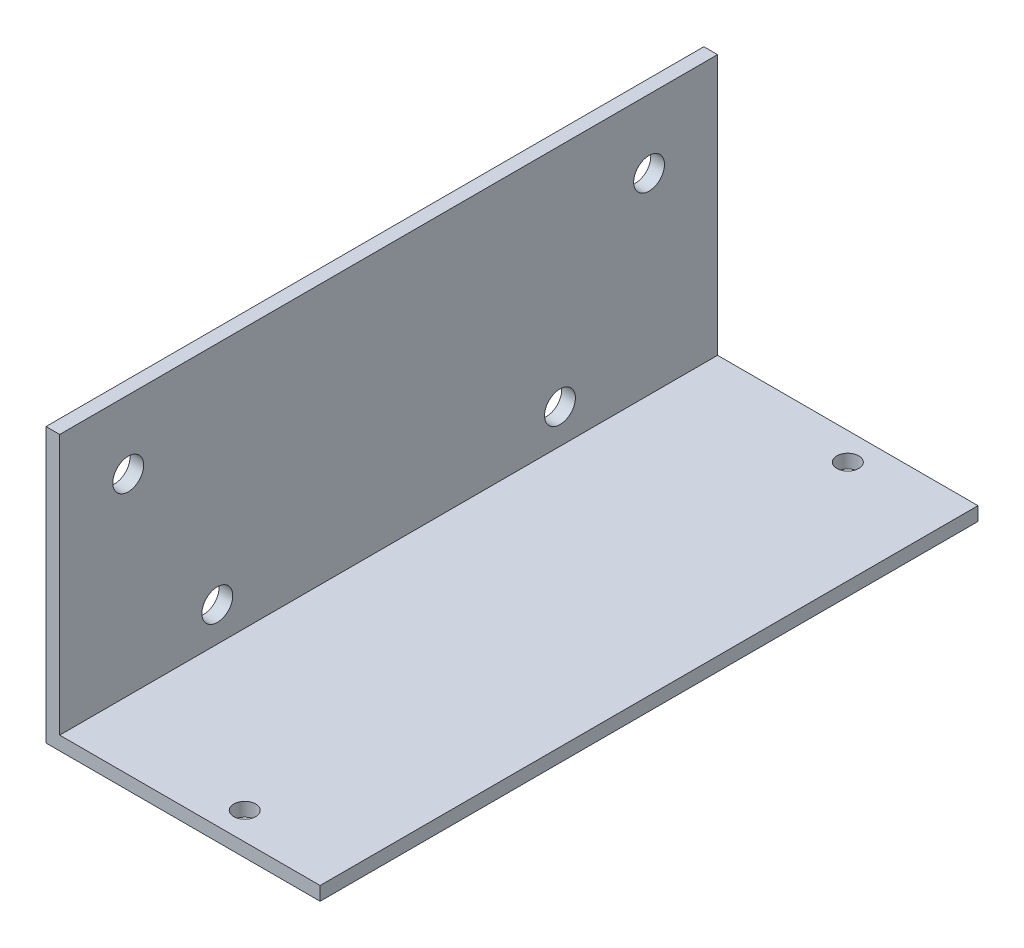
from build123d import *

# Parameters (mm, degrees)
EXTRUDE_1_DEPTH     = 96
SKETCH_2_R          = 1.6
CUT_EXTRUDE_1_DEPTH = 41
SKETCH_3_R          = 2.25
CUT_EXTRUDE_2_DEPTH = 41


with BuildPart() as part:
    # Эскиз1 → Бобышка-Вытянуть1 (new body)
    with BuildSketch(Plane.XY):
        Polygon((0, 0), (40, 0), (40, 2), (2, 2), (2, 40), (0, 40), align=None)
    extrude(amount=EXTRUDE_1_DEPTH)

    # Эскиз2 → Вырез-Вытянуть1 (cut, through all)
    with BuildSketch(Plane.XZ):
        with Locations((25, 92)):
            Circle(SKETCH_2_R)
        with Locations((25, 4)):
            Circle(SKETCH_2_R)
    extrude(amount=-CUT_EXTRUDE_1_DEPTH, mode=Mode.SUBTRACT)

    # Эскиз3 → Вырез-Вытянуть2 (cut, through all)
    with BuildSketch(Plane.ZY):
        with Locations((10, 30)):
            Circle(SKETCH_3_R)
        with Locations((86, 30)):
            Circle(SKETCH_3_R)
        with Locations((73, 7)):
            Circle(SKETCH_3_R)
        with Locations((23, 7)):
            Circle(SKETCH_3_R)
    extrude(amount=-CUT_EXTRUDE_2_DEPTH, mode=Mode.SUBTRACT)


solid = part.part
